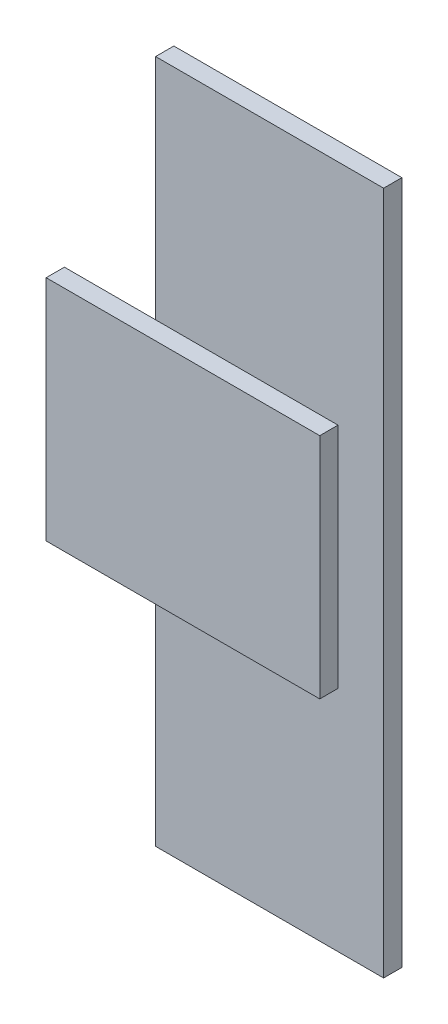
from build123d import *

# Parameters (mm, degrees)
SKETCH1_W           = 50
SKETCH1_H           = 150
BOSS_EXTRUDE1_DEPTH = 4
SKETCH2_W           = 60
SKETCH2_H           = 50
BOSS_EXTRUDE2_DEPTH = 4


with BuildPart() as part:
    # Sketch1 → Boss-Extrude1 (new body)
    with BuildSketch(Plane.XY):
        with Locations((25, 75)):
            Rectangle(SKETCH1_W, SKETCH1_H)
    extrude(amount=BOSS_EXTRUDE1_DEPTH)

    # Sketch2 → Boss-Extrude2 (add)
    with BuildSketch(Plane.XY.offset(4)):
        with Locations((10, 75)):
            Rectangle(SKETCH2_W, SKETCH2_H)
    extrude(amount=BOSS_EXTRUDE2_DEPTH)


solid = part.part
